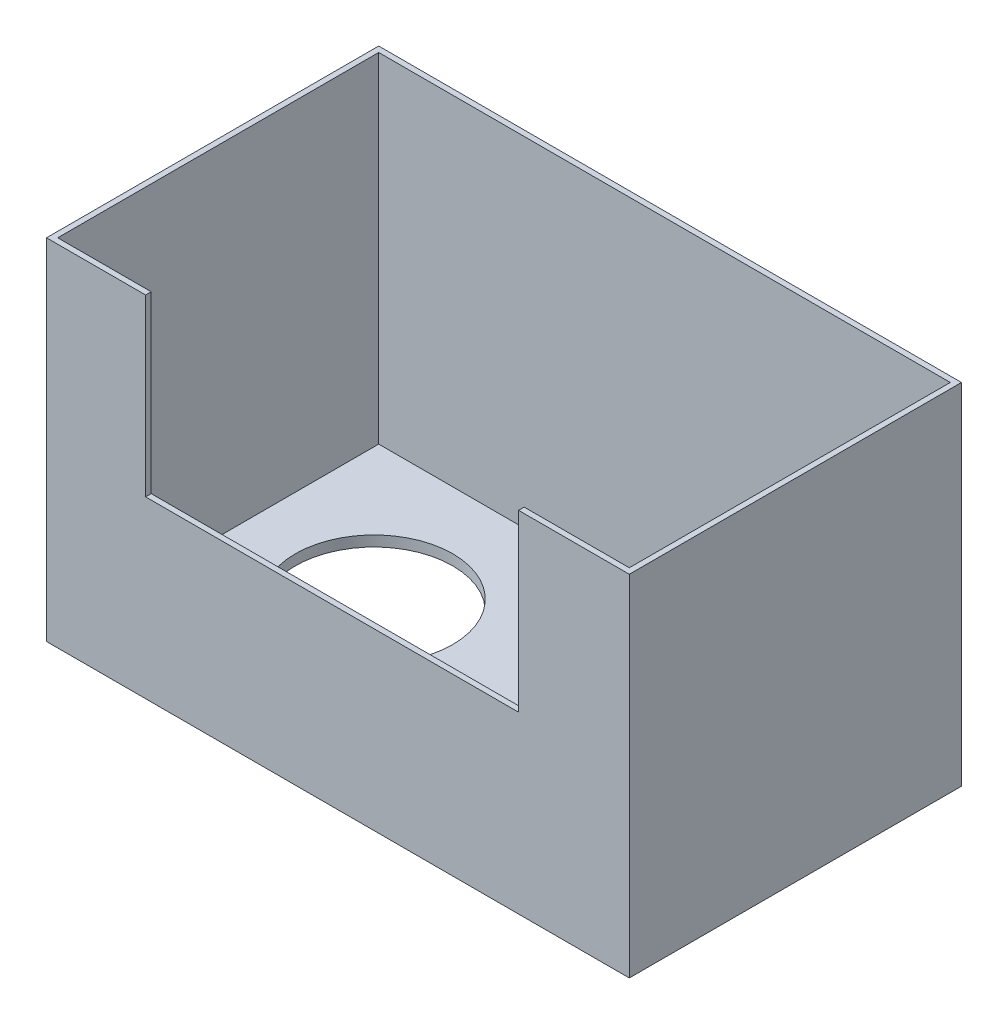
from build123d import *

# Parameters (mm, degrees)
SKETCH1_W           = 127
SKETCH1_H           = 72.39
BOSS_EXTRUDE1_DEPTH = 76.2
SKETCH2_W           = 124.5616
SKETCH2_H           = 69.9516
CUT_EXTRUDE1_DEPTH  = 73.914
SKETCH4_W           = 81.28
SKETCH4_H           = 38.1
CUT_EXTRUDE2_DEPTH  = 1.2192
SKETCH5_R           = 17.145
CUT_EXTRUDE3_DEPTH  = 2.286


with BuildPart() as part:
    # Sketch1 → Boss-Extrude1 (new body)
    with BuildSketch(Plane(origin=(0, 0, 0), x_dir=(1, 0, 0), z_dir=(0, 1, 0))):
        Rectangle(SKETCH1_W, SKETCH1_H)
    extrude(amount=BOSS_EXTRUDE1_DEPTH)

    # Sketch2 → Cut-Extrude1 (cut)
    with BuildSketch(Plane(origin=(0, 76.2, 0), x_dir=(1, 0, 0), z_dir=(0, 1, 0))):
        Rectangle(SKETCH2_W, SKETCH2_H)
    extrude(amount=-CUT_EXTRUDE1_DEPTH, mode=Mode.SUBTRACT)

    # Sketch4 → Cut-Extrude2 (cut)
    with BuildSketch(Plane.XY.offset(36.195)):
        with Locations((-1.27, 57.15)):
            Rectangle(SKETCH4_W, SKETCH4_H)
    extrude(amount=-CUT_EXTRUDE2_DEPTH, mode=Mode.SUBTRACT)

    # Sketch5 → Cut-Extrude3 (cut)
    with BuildSketch(Plane.XZ):
        with Locations((-33.528, -5.207)):
            Circle(SKETCH5_R)
        with Locations((33.528, -5.207)):
            Circle(SKETCH5_R)
    extrude(amount=-CUT_EXTRUDE3_DEPTH, mode=Mode.SUBTRACT)


solid = part.part
